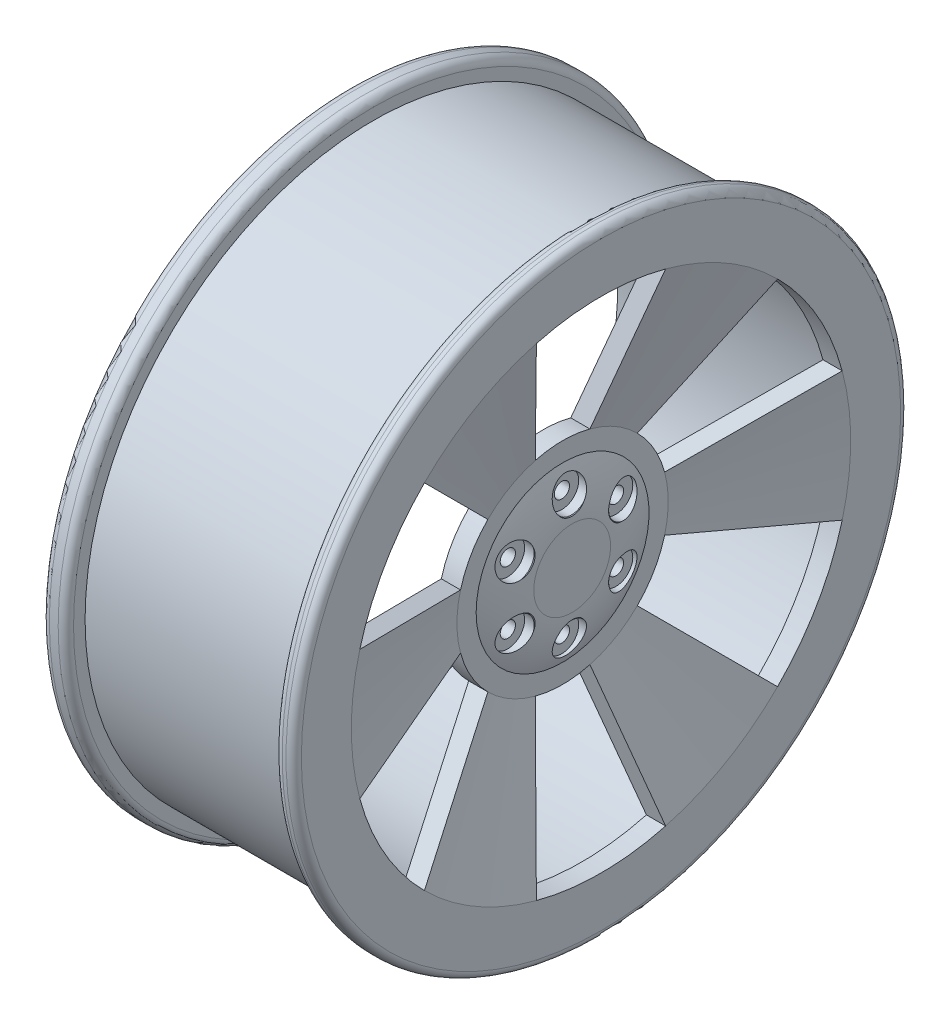
from build123d import *

# Parameters (mm, degrees)
SKETCH1_R           = 190.5
BOSS_EXTRUDE1_DEPTH = 166.624
SKETCH4_R           = 203.2
BOSS_EXTRUDE2_DEPTH = 12.7
SKETCH5_R           = 203.2
BOSS_EXTRUDE3_DEPTH = 16.002
SKETCH6_R           = 177.8
CUT_EXTRUDE2_DEPTH  = 153.924
SKETCH7_R           = 165.1
CUT_EXTRUDE3_DEPTH  = 12.7
FILLET1_R           = 5.08
CUT_EXTRUDE4_DEPTH  = 50.8
CIRPATTERN1_COUNT   = 6
SKETCH12_R          = 25.4
BOSS_EXTRUDE4_DEPTH = 6.35
CIRPATTERN3_COUNT   = 6


with BuildPart() as part:
    # Sketch1 → Boss-Extrude1 (new body)
    with BuildSketch(Plane(origin=(0, 0, 0), x_dir=(0, 0, -1), z_dir=(1, 0, 0))):
        Circle(SKETCH1_R)
    extrude(amount=BOSS_EXTRUDE1_DEPTH)

    # Sketch4 → Boss-Extrude2 (add)
    with BuildSketch(Plane(origin=(166.624, 0, 0), x_dir=(0, 0, -1), z_dir=(1, 0, 0))):
        Circle(SKETCH4_R)
    extrude(amount=-BOSS_EXTRUDE2_DEPTH)

    # Sketch5 → Boss-Extrude3 (add)
    with BuildSketch(Plane.ZY):
        Circle(SKETCH5_R)
    extrude(amount=-BOSS_EXTRUDE3_DEPTH)

    # Sketch6 → Cut-Extrude2 (cut)
    with BuildSketch(Plane.ZY):
        Circle(SKETCH6_R)
    extrude(amount=-CUT_EXTRUDE2_DEPTH, mode=Mode.SUBTRACT)

    # Sketch7 → Cut-Extrude3 (cut)
    with BuildSketch(Plane(origin=(166.624, 0, 0), x_dir=(0, 0, -1), z_dir=(1, 0, 0))):
        Circle(SKETCH7_R)
    extrude(amount=-CUT_EXTRUDE3_DEPTH, mode=Mode.SUBTRACT)

    # Fillet1
    fillet1_edges = [part.edges().sort_by_distance(p)[0] for p in [
        (16.002, 0, -203.2),
        (0, 0, -203.2),
        (153.924, 0, 203.2),
        (166.624, 0, 203.2),
    ]]
    fillet(fillet1_edges, radius=FILLET1_R)

    # Sketch9 → Revolve1 (revolve)
    with BuildSketch(Plane.XY):
        Polygon((141.224, 69.85), (141.224, 0), (128.524, 0), (128.524, 69.85), (153.924, 165.1), (166.624, 165.1), align=None)
    revolve(axis=Axis((141.224, 0, 0), (-1, 0, 0)))

    # Sketch10 → Cut-Extrude4 (cut)
    with BuildSketch(Plane.ZY.offset(-128.524)):
        with BuildLine():
            Line((18.0785103, 67.469918966), (42.731024346, 159.47435392))
            ThreePointArc((42.731024346, 159.47435392), (0, 165.1), (-42.731024346, 159.47435392))
            Line((-42.731024346, 159.47435392), (-18.0785103, 67.469918966))
            ThreePointArc((-18.0785103, 67.469918966), (0, 69.85), (18.0785103, 67.469918966))
        make_face()
    cut_extrude4 = extrude(amount=-CUT_EXTRUDE4_DEPTH, mode=Mode.SUBTRACT)

    # CirPattern1: Cut-Extrude4 ×6 about axis
    cirpattern1_axis = Axis((0, 0, 0), (1, 0, 0))
    for i in range(1, CIRPATTERN1_COUNT):
        add(cut_extrude4.rotate(cirpattern1_axis, i * 360 / CIRPATTERN1_COUNT), mode=Mode.SUBTRACT)

    # Sketch12 → Boss-Extrude4 (add)
    with BuildSketch(Plane(origin=(141.224, 0, 0), x_dir=(0, 0, -1), z_dir=(1, 0, 0))):
        Circle(SKETCH12_R)
    extrude(amount=BOSS_EXTRUDE4_DEPTH)

    # Sketch13 → Revolve2 (revolve)
    with BuildSketch(Plane.XY):
        with BuildLine():
            Line((147.574, 25.4), (141.224, 25.4))
            Line((141.224, 25.4), (141.224, 57.15))
            ThreePointArc((141.224, 57.15), (145.970934778, 41.589386956), (147.574, 25.4))
        make_face()
    revolve(axis=Axis((-8.3312, 0, 0), (1, 0, 0)))

    # Sketch19 → CBORE for 3/8 Hex Cap Screw2 (revolve, cut)
    with BuildSketch(Plane(origin=(147.574, 41.275, 0), x_dir=(0, 0, -1), z_dir=(0, 1, 0))):
        Polygon((0, 0), (0, 147.574), (5.0419, 147.574), (5.0419, 6.8072), (11.1125, 6.8072), (11.1125, 0.532828266), (11.7475, 0), align=None)
    cbore_for_3_8_hex_cap_screw2 = revolve(axis=Axis((153.924, 41.275, 0), (-1, 0, 0)), mode=Mode.SUBTRACT)

    # CirPattern3: CBORE for 3/8 Hex Cap Screw2 ×6 about axis
    cirpattern3_axis = Axis((0, 0, 0), (1, 0, 0))
    for i in range(1, CIRPATTERN3_COUNT):
        add(cbore_for_3_8_hex_cap_screw2.rotate(cirpattern3_axis, i * 360 / CIRPATTERN3_COUNT), mode=Mode.SUBTRACT)


solid = part.part
